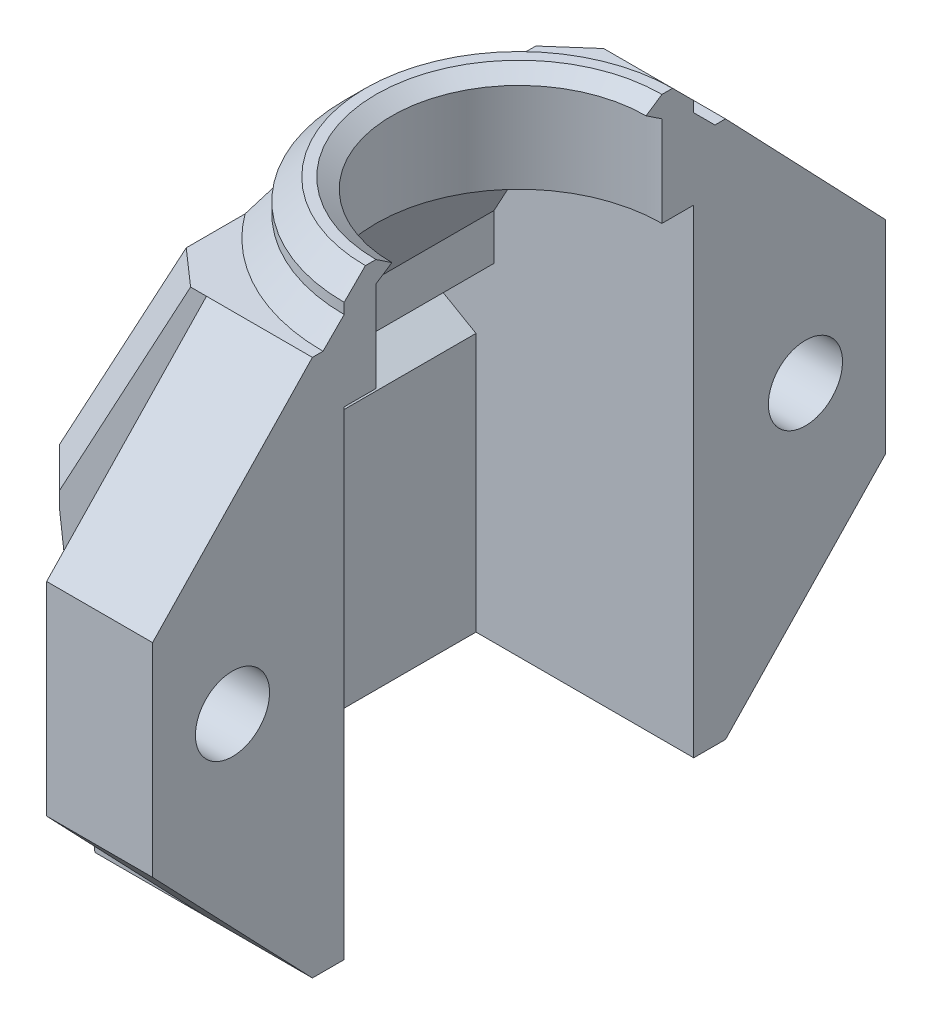
from build123d import *

# Parameters (mm, degrees)
BOSS_EXTRUDE1_DEPTH = 19.5
BOSS_EXTRUDE5_DEPTH = 1.5
BOSS_EXTRUDE6_DEPTH = 1.5
SKETCH8_R           = 6.75
CUT_EXTRUDE2_DEPTH  = 35.70752685
BOSS_EXTRUDE7_DEPTH = 2.5
SKETCH10_R          = 1.75
BOSS_EXTRUDE8_DEPTH = 5
CHAMFER1_SIZE       = 1.5
CHAMFER2_SIZE       = 1
SKETCH11_R          = 2.875
SKETCH11_R_2        = 1.75
CUT_EXTRUDE4_DEPTH  = 2.5
REVOLVE1_ANGLE      = 180
CHAMFER3_SIZE       = 1


with BuildPart() as part:
    # Sketch1 → Boss-Extrude1 (new body)
    with BuildSketch(Plane.XY):
        Polygon((-11.779, -12.684829289), (-10.279, -12.684829289), (-10.279, -0.473504424), (-11.944063509, 0.487820441), (-11.944063509, 1.64252098), (-9.912974596, 2.815170711), (-9.427494989, 2.815170711), (-9.427494989, 4.973204454), (-6.75, 9.910826582), (0, 9.910826582), (0, 12.684829289), (-7.456216647, 12.684829289), (-13.444063509, 1.64252098), (-13.444063509, 0.487820441), align=None)
    extrude(amount=BOSS_EXTRUDE1_DEPTH)

    # Sketch6 → Boss-Extrude5 (add)
    with BuildSketch(Plane.XY.offset(19.5)):
        Polygon((0, 12.684829289), (-7.456216647, 12.684829289), (-13.444063509, 1.64252098), (-13.444063509, 0.487820441), (-11.779, -12.684829289), (0, -12.684829289), align=None)
    extrude(amount=-BOSS_EXTRUDE5_DEPTH)

    # Sketch7 → Boss-Extrude6 (add)
    with BuildSketch(Plane(origin=(0, 0, 0), x_dir=(-1, 0, 0), z_dir=(0, 0, -1))):
        Polygon((0, 12.684829289), (0, -12.684829289), (11.779, -12.684829289), (13.444063509, 0.487820441), (13.444063509, 1.64252098), (7.456216647, 12.684829289), align=None)
    extrude(amount=-BOSS_EXTRUDE6_DEPTH)

    # Sketch8 → Cut-Extrude2 (cut, through all)
    with BuildSketch(Plane(origin=(0, 12.684829289, 0), x_dir=(1, 0, 0), z_dir=(0, 1, 0))):
        with Locations((0, -9.75)):
            Circle(SKETCH8_R)
    extrude(amount=-CUT_EXTRUDE2_DEPTH, mode=Mode.SUBTRACT)

    # Sketch9 → Boss-Extrude7 (add, symmetric)
    with BuildSketch(Plane(origin=(0, 12.684829289, 0), x_dir=(1, 0, 0), z_dir=(0, 1, 0))):
        with BuildLine():
            Line((0, -1.5), (0, -3))
            ThreePointArc((0, -3), (-6.75, -9.75), (0, -16.5))
            Line((0, -16.5), (0, -18))
            ThreePointArc((0, -18), (-8.25, -9.75), (0, -1.5))
        make_face()
    extrude(amount=BOSS_EXTRUDE7_DEPTH, both=True)

    # Sketch10 → Boss-Extrude8 (add)
    with BuildSketch(Plane(origin=(0, 0, 0), x_dir=(0, 0, -1), z_dir=(1, 0, 0))):
        Polygon((-19.5, 12.684829289), (-27.043783602, 4.79693847), (-27.043783602, -4.79693847), (-19.5, -12.684829289), align=None)
        Polygon((-20.396891801, -1.659882024), (-20.396891801, 1.659882024), (-23.271891801, 3.319764048), (-26.146891801, 1.659882024), (-26.146891801, -1.659882024), (-23.271891801, -3.319764048), align=None, mode=Mode.SUBTRACT)
        Polygon((-23.271891801, -3.319764048), (-20.396891801, -1.659882024), (-20.396891801, 1.659882024), (-23.271891801, 3.319764048), (-26.146891801, 1.659882024), (-26.146891801, -1.659882024), align=None)
        with Locations(Location((-23.271891801, 0, 0), (0, 0, 90))):
            Circle(SKETCH10_R, mode=Mode.SUBTRACT)
        Polygon((7.543783602, 4.79693847), (0, 12.684829289), (0, -12.684829289), (7.543783602, -4.79693847), align=None)
        Polygon((6.646891801, 1.659882024), (3.771891801, 3.319764048), (0.896891801, 1.659882024), (0.896891801, -1.659882024), (3.771891801, -3.319764048), (6.646891801, -1.659882024), align=None, mode=Mode.SUBTRACT)
        Polygon((6.646891801, 1.659882024), (6.646891801, -1.659882024), (3.771891801, -3.319764048), (0.896891801, -1.659882024), (0.896891801, 1.659882024), (3.771891801, 3.319764048), align=None)
        with Locations(Location((3.771891801, 0, 0), (0, 0, 90))):
            Circle(SKETCH10_R, mode=Mode.SUBTRACT)
    extrude(amount=-BOSS_EXTRUDE8_DEPTH)

    # Chamfer1
    chamfer1_edges = [part.edges().sort_by_distance(p)[0] for p in [
        (-12.611531755, -6.098504424, 19.5),
        (-13.444063509, 1.065170711, 19.5),
        (-10.450140078, 7.163675135, 19.5),
        (-12.611531755, -6.098504424, 0),
        (-13.444063509, 1.065170711, 0),
        (-10.450140078, 7.163675135, 0),
    ]]
    chamfer(chamfer1_edges, length=CHAMFER1_SIZE)

    # Chamfer2
    chamfer2_edges = [part.edges().sort_by_distance(p)[0] for p in [
        (-8.25, 15.184829289, 9.75),
    ]]
    chamfer(chamfer2_edges, length=CHAMFER2_SIZE)

    # Sketch11 → Cut-Extrude4 (cut)
    with BuildSketch(Plane.ZY.offset(5)):
        with Locations(Location((-3.771891801, 0, 0), (0, 0, 270))):
            Circle(SKETCH11_R)
        with Locations(Location((-3.771891801, 0, 0), (0, 0, 90))):
            Circle(SKETCH11_R_2, mode=Mode.SUBTRACT)
        with Locations(Location((23.271891801, 0, 0), (0, 0, 270))):
            Circle(SKETCH11_R)
        with Locations(Location((23.271891801, 0, 0), (0, 0, 90))):
            Circle(SKETCH11_R_2, mode=Mode.SUBTRACT)
    extrude(amount=-CUT_EXTRUDE4_DEPTH, mode=Mode.SUBTRACT)

    # Sketch12 → Revolve1 (revolve)
    with BuildSketch(Plane(origin=(0, 0, 0), x_dir=(0, 0, -1), z_dir=(1, 0, 0))):
        Polygon((-16.5, 15.184829289), (-16.5, 14.184829289), (-15.75, 14.684829289), align=None)
    revolve(axis=Axis((0, 15.184829289, 9.75), (0, -1, 0)), revolution_arc=REVOLVE1_ANGLE)

    # Chamfer3
    chamfer3_edges = [part.edges().sort_by_distance(p)[0] for p in [
        (-4.412056396, 12.684829289, 2.77889834),
        (-4.412056396, 12.684829289, 16.72110166),
    ]]
    chamfer(chamfer3_edges, length=CHAMFER3_SIZE)


solid = part.part
